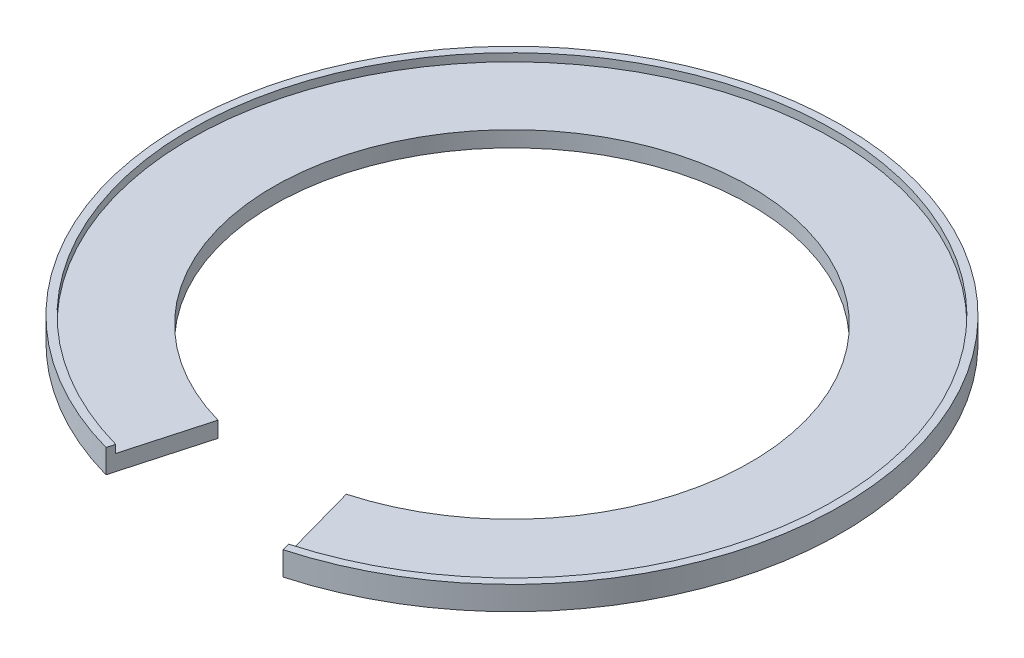
from build123d import *

# Parameters (mm, degrees)
ESBO_O1_R                  = 41.75
ESBO_O1_R_2                = 30.228395062
RESSALTO_EXTRUS_O1_DEPTH   = 2
ESBO_O3_R                  = 41.75
ESBO_O3_R_2                = 40.75
RESSALTO_EXTRUS_O2_DEPTH   = 1
CORTE_EXTRUS_O1_DEPTH      = 2
CORTE_EXTRUS_O1_DEPTH_BACK = 3


with BuildPart() as part:
    # Esboço1 → Ressalto-extrusão1 (new body)
    with BuildSketch(Plane(origin=(0, 0, 0), x_dir=(1, 0, 0), z_dir=(0, 1, 0))):
        Circle(ESBO_O1_R)
        Circle(ESBO_O1_R_2, mode=Mode.SUBTRACT)
    extrude(amount=RESSALTO_EXTRUS_O1_DEPTH)

    # Esboço3 → Ressalto-extrusão2 (add)
    with BuildSketch(Plane(origin=(0, 2, 0), x_dir=(1, 0, 0), z_dir=(0, 1, 0))):
        Circle(ESBO_O3_R)
        Circle(ESBO_O3_R_2, mode=Mode.SUBTRACT)
    extrude(amount=RESSALTO_EXTRUS_O2_DEPTH)

    # Esboço2 → Corte-extrusão1 (cut, two sides)
    with BuildSketch(Plane(origin=(0, 2, 0), x_dir=(1, 0, 0), z_dir=(0, 1, 0))) as corte_extrus_o1_sk:
        with BuildLine():
            Line((12.293139319, -44.064007213), (7.927300358, -28.414924055))
            ThreePointArc((7.927300358, -28.414924055), (0, -29.5), (-7.927300358, -28.414924055))
            Line((-7.927300358, -28.414924055), (-12.293139319, -44.064007213))
            ThreePointArc((-12.293139319, -44.064007213), (0, -45.746672076), (12.293139319, -44.064007213))
        make_face()
    extrude(amount=CORTE_EXTRUS_O1_DEPTH, mode=Mode.SUBTRACT)
    extrude(corte_extrus_o1_sk.sketch, amount=-CORTE_EXTRUS_O1_DEPTH_BACK, mode=Mode.SUBTRACT)


solid = part.part
